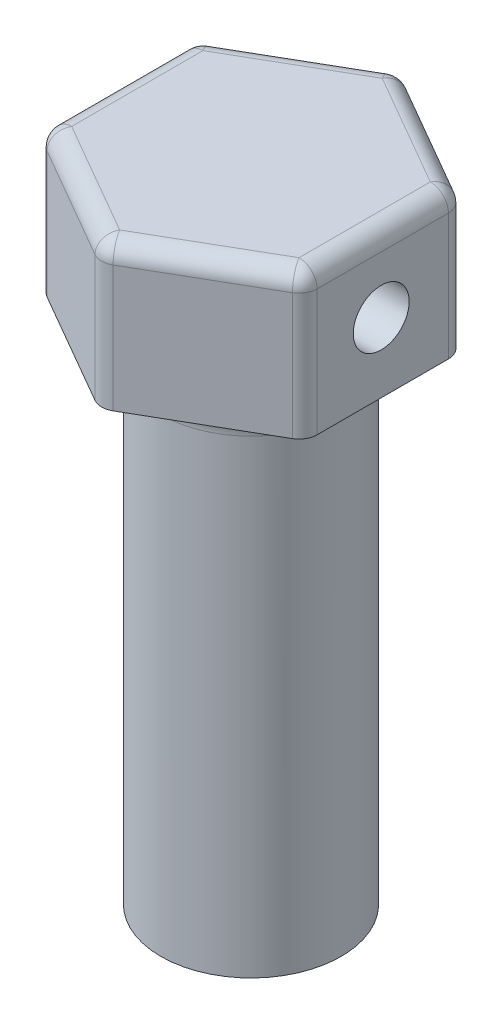
from build123d import *

# Parameters (mm, degrees)
BOSS_EXTRUDE1_DEPTH     = 8
SKETCH2_R               = 5
BOSS_EXTRUDE2_DEPTH     = 28
FILLET1_R               = 2
SKETCH3_R               = 1.55
CUT_EXTRUDE1_DEPTH      = 33.683533061
FILLET2_R               = 1
CUT_EXTRUDE3_START      = -4
SKETCH5_R               = 2.1
CUT_EXTRUDE3_DEPTH      = 4
SKETCH6_R               = 0.5
CUT_EXTRUDE4_DEPTH      = 0.5
CUT_EXTRUDE5_REACH      = 32.096
CUT_EXTRUDE5_END_RADIUS = 1.55
SKETCH7_R               = 1


with BuildPart() as part:
    # Sketch1 → Boss-Extrude1 (new body)
    with BuildSketch(Plane(origin=(0, 0, 0), x_dir=(1, 0, 0), z_dir=(0, 1, 0))):
        Polygon((7.3, -4.214656965), (7.3, 4.214656965), (0, 8.42931393), (-7.3, 4.214656965), (-7.3, -4.214656965), (0, -8.42931393), align=None)
    extrude(amount=BOSS_EXTRUDE1_DEPTH)

    # Sketch2 → Boss-Extrude2 (add)
    with BuildSketch(Plane.XZ):
        Circle(SKETCH2_R)
        with BuildLine():
            Line((-1.55, 1.416862732), (-1.55, -1.416862732))
            ThreePointArc((-1.55, -1.416862732), (2.1, 0), (-1.55, 1.416862732))
        make_face(mode=Mode.SUBTRACT)
    extrude(amount=BOSS_EXTRUDE2_DEPTH)

    # Fillet1
    fillet1_edges = [part.edges().sort_by_distance(p)[0] for p in [
        (-5, 0, 0),
    ]]
    fillet(fillet1_edges, radius=FILLET1_R)

    # Sketch3 → Cut-Extrude1 (cut, through all)
    with BuildSketch(Plane(origin=(7.3, 0, 0), x_dir=(0, 0, -1), z_dir=(1, 0, 0))):
        with Locations((-0.085343035, 3.85)):
            Circle(SKETCH3_R)
    extrude(amount=-CUT_EXTRUDE1_DEPTH, mode=Mode.SUBTRACT)

    # Fillet2
    fillet2_edges = [part.edges().sort_by_distance(p)[0] for p in [
        (-3.65, 8, 6.321985448),
        (-7.3, 8, 0),
        (-3.65, 8, -6.321985448),
        (3.65, 8, -6.321985448),
        (7.3, 8, 0),
        (3.65, 8, 6.321985448),
        (-7.3, 4, -4.214656965),
        (0, 4, -8.42931393),
        (7.3, 4, -4.214656965),
        (7.3, 4, 4.214656965),
        (0, 4, 8.42931393),
        (-7.3, 4, 4.214656965),
    ]]
    fillet(fillet2_edges, radius=FILLET2_R)

    # Sketch5 → Cut-Extrude3 (cut)
    with BuildSketch(Plane.XZ.offset(28).offset(CUT_EXTRUDE3_START)):
        Circle(SKETCH5_R)
    extrude(amount=CUT_EXTRUDE3_DEPTH, mode=Mode.SUBTRACT)

    # Sketch6 → Cut-Extrude4 (cut)
    with BuildSketch(Plane(origin=(3.65, 0, -6.321985448), x_dir=(-0.8660254037844388, 0, -0.49999999999999967), z_dir=(0.49999999999999967, 0, -0.8660254037844388))):
        with Locations((0, 3.5)):
            Circle(SKETCH6_R)
        with Locations((-2, 3.5)):
            Circle(SKETCH6_R)
        with Locations((2, 3.5)):
            Circle(SKETCH6_R)
    extrude(amount=-CUT_EXTRUDE4_DEPTH, mode=Mode.SUBTRACT)

    # Cut-Extrude5: up to this cylinder (the profile starts outside it)
    cut_extrude5_end = Plane(origin=(0, 3.85, 0.085343035), z_dir=(1, 0, 0)) * Cylinder(CUT_EXTRUDE5_END_RADIUS, 68.292, mode=Mode.PRIVATE)
    # Sketch7 → Cut-Extrude5 (cut, up to the surface)
    with BuildSketch(Plane.XZ, mode=Mode.PRIVATE) as cut_extrude5_sk1:
        Circle(SKETCH7_R)
    cut_extrude5_tool1 = extrude(cut_extrude5_sk1.sketch, amount=-CUT_EXTRUDE5_REACH, mode=Mode.PRIVATE) - cut_extrude5_end
    add(cut_extrude5_tool1.solids().sort_by_distance((0, 0, 0))[0], mode=Mode.SUBTRACT)


solid = part.part
